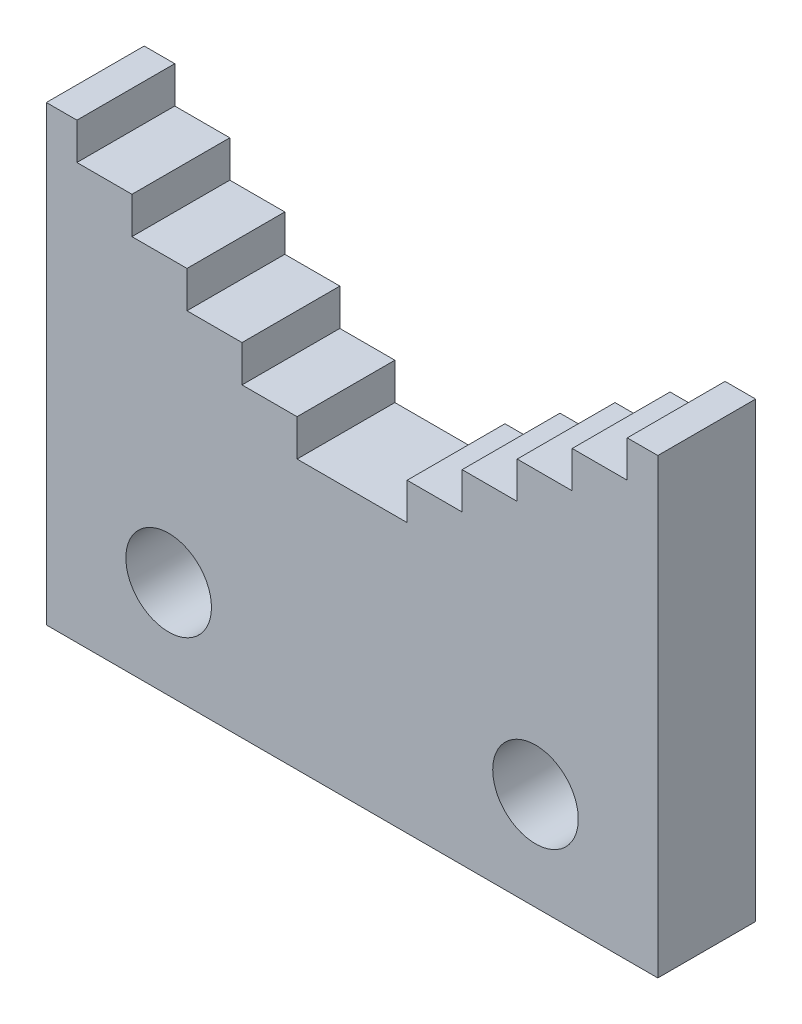
from build123d import *

# Parameters (mm, degrees)
SKETCH1_R           = 3.5
BOSS_EXTRUDE1_DEPTH = 8


with BuildPart() as part:
    # Sketch1 → Boss-Extrude1 (new body)
    with BuildSketch(Plane.XY):
        Polygon((25, 0), (-25, 0), (-25, 37), (-22.5, 37), (-22.5, 34), (-18, 34), (-18, 31), (-13.5, 31), (-13.5, 28), (-9, 28), (-9, 25), (-4.5, 25), (-4.5, 22), (4.5, 22), (4.5, 25), (9, 25), (9, 28), (13.5, 28), (13.5, 31), (18, 31), (18, 34), (22.5, 34), (22.5, 37), (25, 37), align=None)
        with Locations((-15, 8)):
            Circle(SKETCH1_R, mode=Mode.SUBTRACT)
        with Locations((15, 8)):
            Circle(SKETCH1_R, mode=Mode.SUBTRACT)
    extrude(amount=BOSS_EXTRUDE1_DEPTH)


solid = part.part
